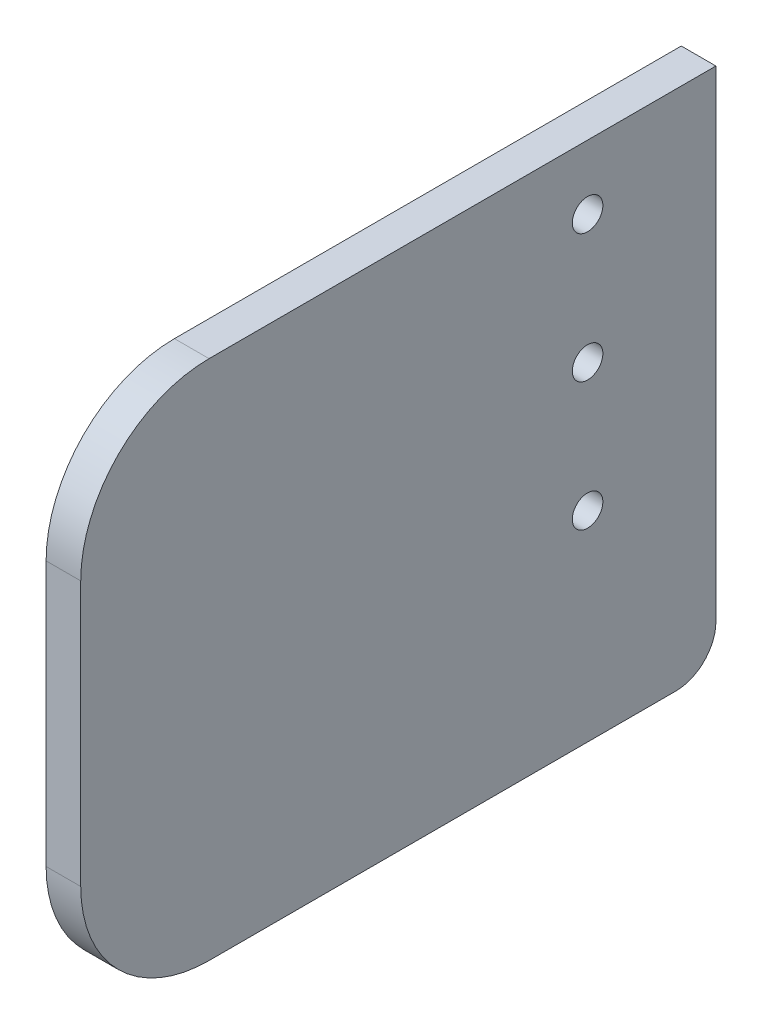
from build123d import *

# Parameters (mm, degrees)
SKETCH1_R           = 1.905
BOSS_EXTRUDE1_DEPTH = 4.318


with BuildPart() as part:
    # Sketch1 → Boss-Extrude1 (new body)
    with BuildSketch(Plane(origin=(0, 0, 0), x_dir=(0, 0, -1), z_dir=(1, 0, 0))):
        with BuildLine():
            Line((16, 0), (74.195959493, 0))
            ThreePointArc((74.195959493, 0), (77.731493399, 1.464466094), (79.195959493, 5))
            Line((79.195959493, 5), (79.195959493, 65))
            Line((79.195959493, 65), (16, 65))
            ThreePointArc((16, 65), (4.686291501, 60.313708499), (0, 49))
            Line((0, 49), (0, 16))
            ThreePointArc((0, 16), (4.686291501, 4.686291501), (16, 0))
        make_face()
        with Locations((63.195959493, 57)):
            Circle(SKETCH1_R, mode=Mode.SUBTRACT)
        with Locations((63.195959493, 41)):
            Circle(SKETCH1_R, mode=Mode.SUBTRACT)
        with Locations((63.195959493, 25)):
            Circle(SKETCH1_R, mode=Mode.SUBTRACT)
    extrude(amount=-BOSS_EXTRUDE1_DEPTH)


solid = part.part
